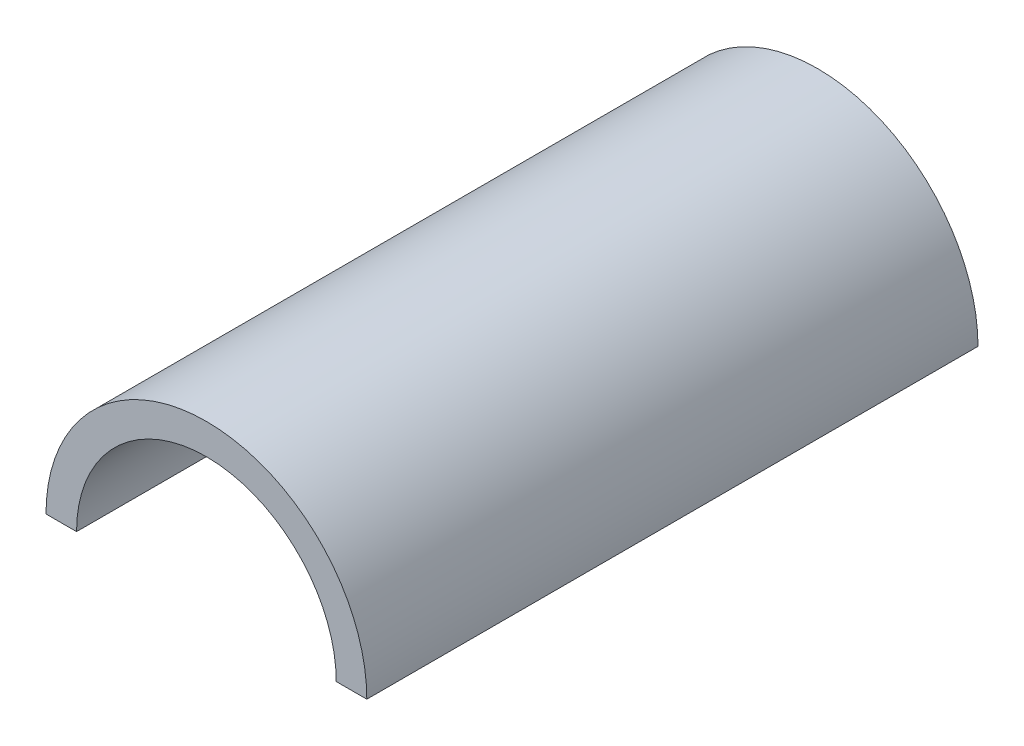
from build123d import *

# Parameters (mm, degrees)
BOSS_EXTRUDE1_DEPTH                   = 139.7
F_1_8_0_125_DIAMETER_HOLE1_AT_2_COUNT = 2
F_1_8_0_125_DIAMETER_HOLE1_AT_2_PITCH = 66.3448
LPATTERN1_COUNT                       = 5
LPATTERN1_PITCH                       = 11.43


with BuildPart() as part:
    # Sketch1 → Boss-Extrude1 (new body)
    with BuildSketch(Plane.XY):
        with BuildLine():
            Line((-37.544302716, 7.712013675), (-44.529302716, 7.712013675))
            ThreePointArc((-44.529302716, 7.712013675), (-7.864402716, 44.376913675), (28.800497284, 7.712013675))
            Line((28.800497284, 7.712013675), (21.815497284, 7.712013675))
            ThreePointArc((21.815497284, 7.712013675), (-7.864402716, 37.391913675), (-37.544302716, 7.712013675))
        make_face()
    extrude(amount=BOSS_EXTRUDE1_DEPTH)

    # Sketch4 → 1/8 (0.125) Diameter Hole1 (revolve, cut)
    with BuildSketch(Plane(origin=(-41.036802716, 7.712013675, 76.2), x_dir=(0, 0, -1), z_dir=(1, 0, 0))):
        Polygon((0, 0), (0, 1.453866233), (1.5875, 0.5), (1.5875, 0), align=None)
    f_1_8_0_125_diameter_hole1 = revolve(axis=Axis((-41.036802716, 1.362013675, 76.2), (0, 1, 0)), mode=Mode.SUBTRACT)

    # 1/8 (0.125) Diameter Hole1 at 2: 1/8 (0.125) Diameter Hole1 ×2
    with Locations(*[(i * F_1_8_0_125_DIAMETER_HOLE1_AT_2_PITCH, 0, 0) for i in range(1, F_1_8_0_125_DIAMETER_HOLE1_AT_2_COUNT)]):
        add(f_1_8_0_125_diameter_hole1, mode=Mode.SUBTRACT)

    # LPattern1: 1/8 (0.125) Diameter Hole1 ×5
    with Locations(*[(0, 0, -i * LPATTERN1_PITCH) for i in range(1, LPATTERN1_COUNT)]):
        add(f_1_8_0_125_diameter_hole1, mode=Mode.SUBTRACT)

    # LPattern1 copy 1 sketch → LPattern1 copy 1 (revolve, cut)
    with BuildSketch(Plane(origin=(25.307997284, 7.712013675, 64.77), x_dir=(0, 0, -1), z_dir=(1, 0, 0))):
        Polygon((0, 0), (0, 1.453866233), (1.5875, 0.5), (1.5875, 0), align=None)
    revolve(axis=Axis((25.307997284, 1.362013675, 64.77), (0, 1, 0)), mode=Mode.SUBTRACT)

    # LPattern1 copy 2 sketch → LPattern1 copy 2 (revolve, cut)
    with BuildSketch(Plane(origin=(25.307997284, 7.712013675, 53.34), x_dir=(0, 0, -1), z_dir=(1, 0, 0))):
        Polygon((0, 0), (0, 1.453866233), (1.5875, 0.5), (1.5875, 0), align=None)
    revolve(axis=Axis((25.307997284, 1.362013675, 53.34), (0, 1, 0)), mode=Mode.SUBTRACT)

    # LPattern1 copy 3 sketch → LPattern1 copy 3 (revolve, cut)
    with BuildSketch(Plane(origin=(25.307997284, 7.712013675, 41.91), x_dir=(0, 0, -1), z_dir=(1, 0, 0))):
        Polygon((0, 0), (0, 1.453866233), (1.5875, 0.5), (1.5875, 0), align=None)
    revolve(axis=Axis((25.307997284, 1.362013675, 41.91), (0, 1, 0)), mode=Mode.SUBTRACT)

    # LPattern1 copy 4 sketch → LPattern1 copy 4 (revolve, cut)
    with BuildSketch(Plane(origin=(25.307997284, 7.712013675, 30.48), x_dir=(0, 0, -1), z_dir=(1, 0, 0))):
        Polygon((0, 0), (0, 1.453866233), (1.5875, 0.5), (1.5875, 0), align=None)
    revolve(axis=Axis((25.307997284, 1.362013675, 30.48), (0, 1, 0)), mode=Mode.SUBTRACT)


solid = part.part
